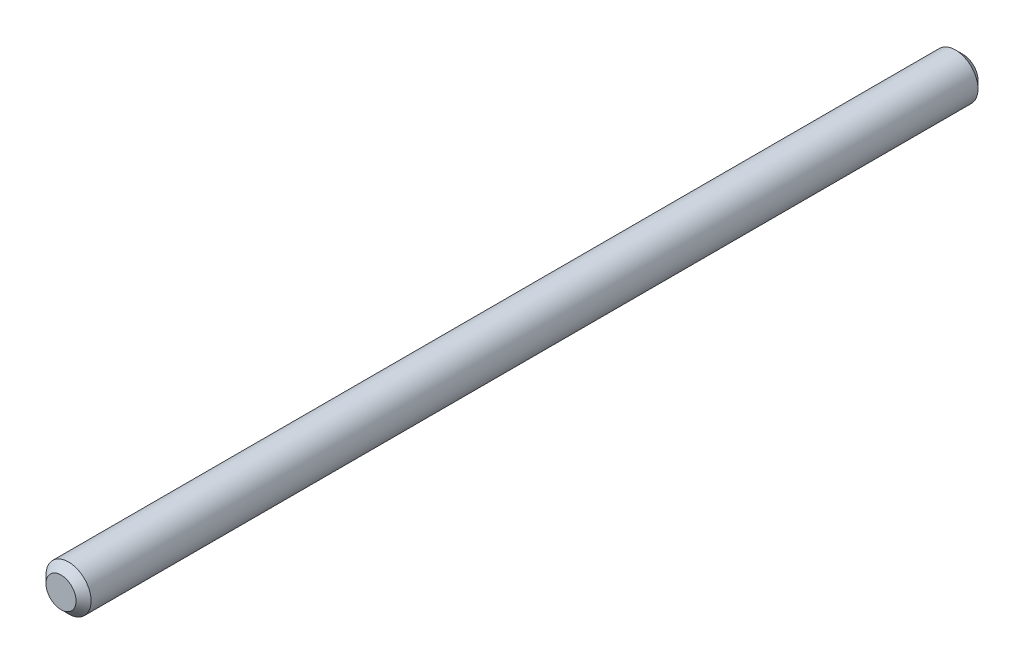
from build123d import *

# Parameters (mm, degrees)
SKIZZE1_R                       = 1.5
AUFSATZ_LINEAR_AUSTRAGEN1_DEPTH = 30
FASE1_SIZE                      = 0.5


with BuildPart() as part:
    # Skizze1 → Aufsatz-Linear austragen1 (new body, symmetric)
    with BuildSketch(Plane.XY):
        Circle(SKIZZE1_R)
    extrude(amount=AUFSATZ_LINEAR_AUSTRAGEN1_DEPTH, both=True)

    # Fase1
    fase1_edges = [part.edges().sort_by_distance(p)[0] for p in [
        (-1.5, 0, -30),
        (-1.5, 0, 30),
    ]]
    chamfer(fase1_edges, length=FASE1_SIZE)


solid = part.part
